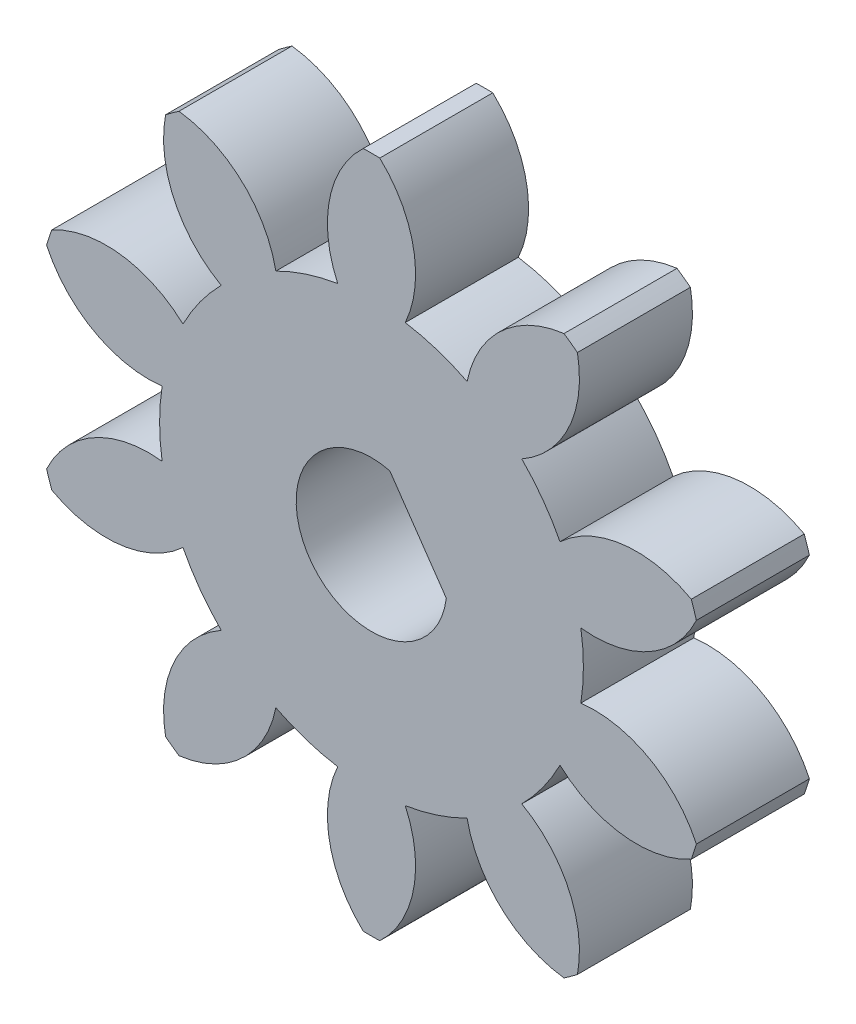
from build123d import *

# Parameters (mm, degrees)
SKETCH1_R           = 9
BOSS_EXTRUDE1_DEPTH = 3
CUT_EXTRUDE1_DEPTH  = 14.076696831
CIRPATTERN1_COUNT   = 10
CUT_EXTRUDE4_DEPTH  = 13.821408374


with BuildPart() as part:
    # Sketch1 → Boss-Extrude1 (new body)
    with BuildSketch(Plane.XY):
        Circle(SKETCH1_R)
    extrude(amount=BOSS_EXTRUDE1_DEPTH)

    # Sketch2 → Cut-Extrude1 (cut, through all)
    with BuildSketch(Plane.XY.offset(3)):
        with BuildLine():
            ThreePointArc((5.110667533, 7.408176386), (3.438910397, 6.629232039), (2.538761327, 5.019493592))
            ThreePointArc((2.538761327, 5.019493592), (1.738220593, 5.349692904), (0.896483249, 5.553102087))
            ThreePointArc((0.896483249, 5.553102087), (1.114427873, 7.384502195), (0.21979994, 8.997315599))
            ThreePointArc((0.21979994, 8.997315599), (2.781152949, 8.559508647), (5.110667533, 7.408176386))
        make_face()
    cut_extrude1 = extrude(amount=-CUT_EXTRUDE1_DEPTH, mode=Mode.SUBTRACT)

    # CirPattern1: Cut-Extrude1 ×10 about axis
    cirpattern1_axis = Axis((0, 0, 0), (0, 0, 1))
    for i in range(1, CIRPATTERN1_COUNT):
        add(cut_extrude1.rotate(cirpattern1_axis, i * 360 / CIRPATTERN1_COUNT), mode=Mode.SUBTRACT)

    # Sketch5 → Cut-Extrude4 (cut, through all)
    with BuildSketch(Plane.XY.offset(3)):
        with BuildLine():
            Line((1.985580324, -0.239730633), (0.486047904, 1.940040575))
            ThreePointArc((0.486047904, 1.940040575), (-1.647752152, -1.133539961), (1.985580324, -0.239730633))
        make_face()
    extrude(amount=-CUT_EXTRUDE4_DEPTH, mode=Mode.SUBTRACT)


solid = part.part
